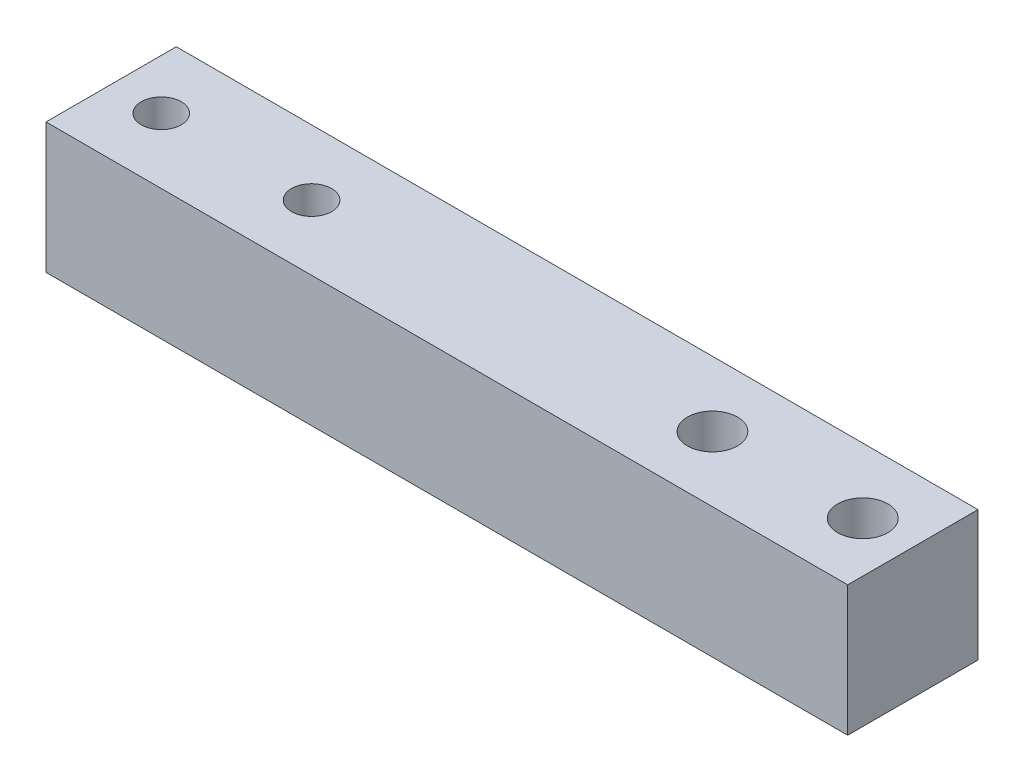
from build123d import *

# Parameters (mm, degrees)
ESQUISSE1_W             = 80
ESQUISSE1_H             = 13
BOSS_EXTRU_1_DEPTH      = 13
ESQUISSE2_R             = 2
ESQUISSE2_R_2           = 2.5
ENL_V_MAT_EXTRU_1_DEPTH = 14


with BuildPart() as part:
    # Esquisse1 → Boss.-Extru.1 (new body)
    with BuildSketch(Plane.XY):
        with Locations((37.457366649, -4.977657935)):
            Rectangle(ESQUISSE1_W, ESQUISSE1_H)
    extrude(amount=BOSS_EXTRU_1_DEPTH)

    # Esquisse2 → Enlèv. mat.-Extru.1 (cut, through all)
    with BuildSketch(Plane(origin=(0, 1.522342065, 0), x_dir=(1, 0, 0), z_dir=(0, 1, 0))):
        with Locations((17.457366649, -6.5)):
            Circle(ESQUISSE2_R)
        with Locations((72.457366649, -6.5)):
            Circle(ESQUISSE2_R_2)
        with Locations((57.457366649, -6.5)):
            Circle(ESQUISSE2_R_2)
        with Locations((2.457366649, -6.5)):
            Circle(ESQUISSE2_R)
    extrude(amount=-ENL_V_MAT_EXTRU_1_DEPTH, mode=Mode.SUBTRACT)


solid = part.part
